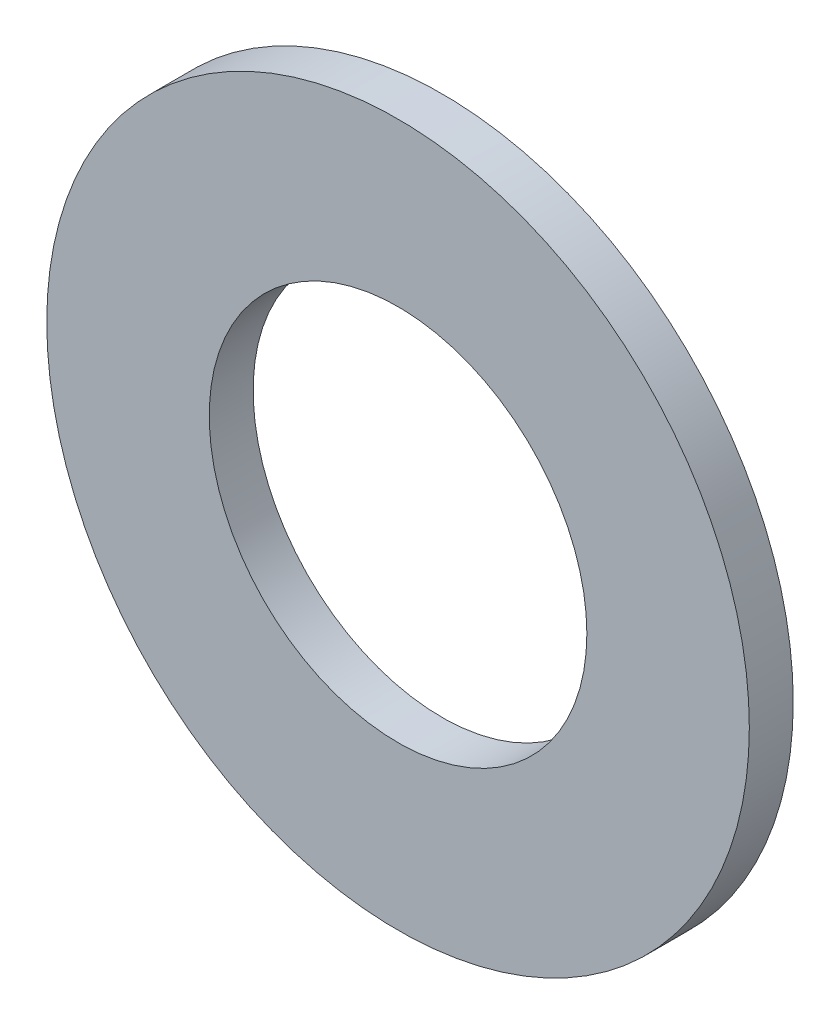
from build123d import *

# Parameters (mm, degrees)
SKETCH_1_R      = 4
SKETCH_1_R_2    = 2.15
EXTRUDE_1_DEPTH = 0.5


with BuildPart() as part:
    # Эскиз1 → Бобышка-Вытянуть1 (new body)
    with BuildSketch(Plane.XY):
        Circle(SKETCH_1_R)
        Circle(SKETCH_1_R_2, mode=Mode.SUBTRACT)
    extrude(amount=EXTRUDE_1_DEPTH)


solid = part.part
